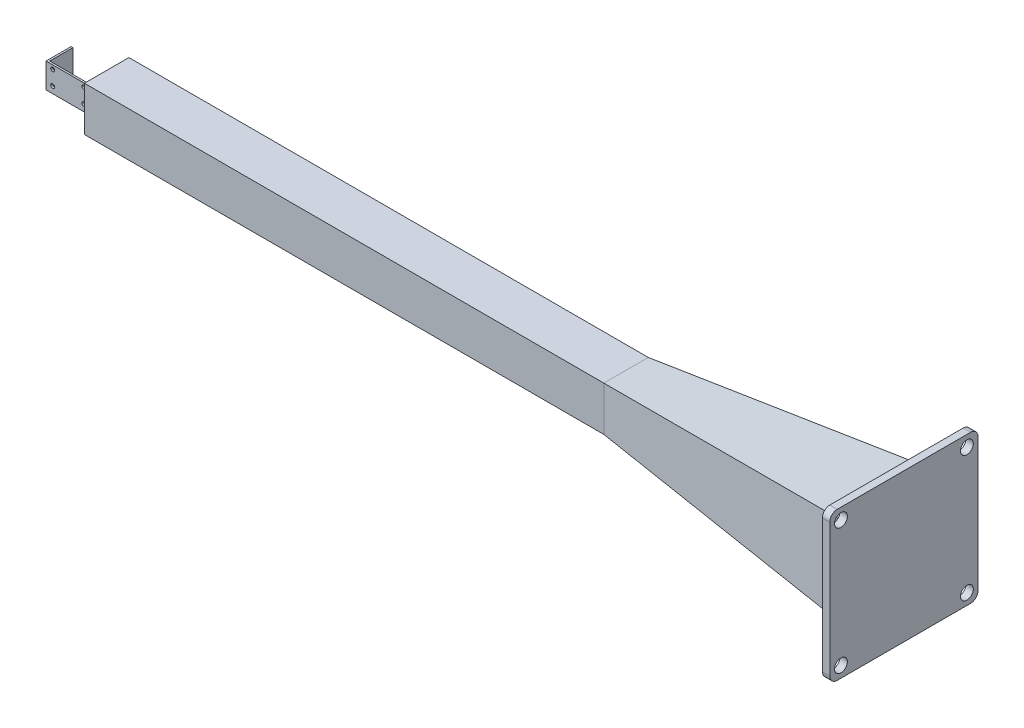
from build123d import *

# Parameters (mm, degrees)
SKETCH1_W            = 220
SKETCH1_H            = 130
SKETCH1_R            = 10.5
BOSS_EXTRUDE1_DEPTH  = 10
BOSS_EXTRUDE2_DEPTH  = 250
CUT_EXTRUDE1_DEPTH   = 5
SKETCH4_W            = 10
SKETCH4_H            = 135
BOSS_EXTRUDE3_DEPTH  = 250
SKETCH5_W            = 250
SKETCH5_H            = 135
BOSS_EXTRUDE4_DEPTH  = 2800
SKETCH8_W            = 115
SKETCH8_H            = 135
CUT_EXTRUDE2_DEPTH   = 10000
SKETCH12_W           = 170
SKETCH12_H           = 170
BOSS_EXTRUDE6_DEPTH  = 2800
CUT_EXTRUDE3_DEPTH   = 50
SKETCH15_W           = 170
SKETCH15_H           = 170
BOSS_EXTRUDE7_DEPTH  = 1524
SKETCH16_W           = 240
SKETCH16_H           = 240
BOSS_EXTRUDE8_DEPTH  = 4324
SKETCH17_W           = 240
SKETCH17_H           = 240
CUT_EXTRUDE4_DEPTH   = 20
SKETCH18_W           = 135
SKETCH18_H           = 135
BOSS_EXTRUDE9_DEPTH  = 20
SKETCH19_W           = 500
SKETCH19_H           = 500
SKETCH20_W           = 240
SKETCH20_H           = 240
SKETCH21_R           = 34.757471725
BOSS_EXTRUDE10_DEPTH = 40


with BuildPart() as part:
    # Sketch1 → Boss-Extrude1 (new body)
    with BuildSketch(Plane.XY):
        with Locations((6.239262286, -1.26777364)):
            Rectangle(SKETCH1_W, SKETCH1_H)
        with Locations((90.239262286, -40.26777364)):
            Circle(SKETCH1_R, mode=Mode.SUBTRACT)
        with Locations((-77.760737714, -40.26777364)):
            Circle(SKETCH1_R, mode=Mode.SUBTRACT)
        with Locations((-77.760737714, 37.73222636)):
            Circle(SKETCH1_R, mode=Mode.SUBTRACT)
        with Locations((90.239262286, 37.73222636)):
            Circle(SKETCH1_R, mode=Mode.SUBTRACT)
    extrude(amount=BOSS_EXTRUDE1_DEPTH)

    # Sketch2 → Boss-Extrude2 (add)
    with BuildSketch(Plane.XY.offset(10)):
        Polygon((-103.760737714, 63.73222636), (-113.760737714, 63.73222636), (-113.760737714, -66.26777364), (-113.760737714, -76.26777364), (116.239262286, -76.26777364), (116.239262286, -66.26777364), (-103.760737714, -66.26777364), align=None)
    extrude(amount=-BOSS_EXTRUDE2_DEPTH)

    # Sketch3 → Cut-Extrude1 (cut)
    with BuildSketch(Plane(origin=(0, 63.73222636, 0), x_dir=(1, 0, 0), z_dir=(0, 1, 0))):
        Polygon((116.239262286, 0), (-103.760737714, 0), (-103.760737714, 240), (-113.760737714, 240), (-113.760737714, -10), (116.239262286, -10), align=None)
    extrude(amount=-CUT_EXTRUDE1_DEPTH, mode=Mode.SUBTRACT)

    # Sketch4 → Boss-Extrude3 (add)
    with BuildSketch(Plane.XY.offset(10)):
        with Locations((121.239262286, -8.76777364)):
            Rectangle(SKETCH4_W, SKETCH4_H)
    extrude(amount=-BOSS_EXTRUDE3_DEPTH)


with BuildPart() as body_2:
    # Sketch5 → Boss-Extrude4 (new body)
    with BuildSketch(Plane(origin=(126.239262286, 0, 0), x_dir=(0, 0, -1), z_dir=(1, 0, 0))):
        with Locations((115, -8.76777364)):
            Rectangle(SKETCH5_W, SKETCH5_H)
    extrude(amount=BOSS_EXTRUDE4_DEPTH)


with BuildPart() as cut_extrude2_tool:
    # Sketch8 → Cut-Extrude2 (new body)
    with BuildSketch(Plane(origin=(2926.239262286, 0, 0), x_dir=(0, 0, -1), z_dir=(1, 0, 0))):
        with Locations((182.5, -8.76777364)):
            Rectangle(SKETCH8_W, SKETCH8_H)
    extrude(amount=-CUT_EXTRUDE2_DEPTH)


with BuildPart() as part_1:
    add(part.part)

    # Cut-Extrude2: cut by cut_extrude2_tool
    add(cut_extrude2_tool.part, mode=Mode.SUBTRACT)



with BuildPart() as body_2_1:
    add(body_2.part)

    # Cut-Extrude2: cut by cut_extrude2_tool
    add(cut_extrude2_tool.part, mode=Mode.SUBTRACT)


with BuildPart() as part_2:
    add(part_1.part)

    add(body_2_1.part)  # Boss-Extrude6 merges body 2
    # Sketch12 → Boss-Extrude6 (add)
    with BuildSketch(Plane(origin=(2926.239262286, 0, 0), x_dir=(0, 0, -1), z_dir=(1, 0, 0))):
        with Locations((57.5, -8.76777364)):
            Rectangle(SKETCH12_W, SKETCH12_H)
    extrude(amount=-BOSS_EXTRUDE6_DEPTH)

    # Sketch14 → Cut-Extrude3 (cut)
    with BuildSketch(Plane.XZ.offset(76.26777364)):
        Polygon((-103.760737714, 0), (116.239262286, 0), (116.239262286, -115), (116.239262286, -125), (-103.760737714, -125), (-103.760737714, -115), align=None)
    extrude(amount=-CUT_EXTRUDE3_DEPTH, mode=Mode.SUBTRACT)

    # Sketch15 → Boss-Extrude7 (add)
    with BuildSketch(Plane(origin=(2926.239262286, 0, 0), x_dir=(0, 0, -1), z_dir=(1, 0, 0))):
        with Locations((57.5, -8.76777364)):
            Rectangle(SKETCH15_W, SKETCH15_H)
    extrude(amount=BOSS_EXTRUDE7_DEPTH)

    # Sketch16 → Boss-Extrude8 (add)
    with BuildSketch(Plane.ZY.offset(-126.239262286)):
        with Locations((-57.5, -8.76777364)):
            Rectangle(SKETCH16_W, SKETCH16_H)
    extrude(amount=-BOSS_EXTRUDE8_DEPTH)

    # Sketch17 → Cut-Extrude4 (cut)
    with BuildSketch(Plane.ZY.offset(-126.239262286)):
        with Locations((-57.5, -8.76777364)):
            Rectangle(SKETCH17_W, SKETCH17_H)
    extrude(amount=-CUT_EXTRUDE4_DEPTH, mode=Mode.SUBTRACT)

    # Sketch18 → Boss-Extrude9 (add)
    with BuildSketch(Plane(origin=(126.239262286, 0, 0), x_dir=(0, 0, -1), z_dir=(1, 0, 0))):
        with Locations((57.5, -8.76777364)):
            Rectangle(SKETCH18_W, SKETCH18_H)
    extrude(amount=BOSS_EXTRUDE9_DEPTH)

    # Sketch19 → Loft1 section 0
    with BuildSketch(Plane(origin=(4450.239262286, 0, 0), x_dir=(0, 0, -1), z_dir=(1, 0, 0))):
        with Locations((57.5, -8.76777364)):
            Rectangle(SKETCH19_W, SKETCH19_H)
    # Sketch20 → Loft1 section 1
    with BuildSketch(Plane(origin=(2950.239262286, 0, 0), x_dir=(0, 0, -1), z_dir=(1, 0, 0))):
        with Locations((57.5, -8.76777364)):
            Rectangle(SKETCH20_W, SKETCH20_H)
    loft()

    # Sketch21 → Boss-Extrude10 (add)
    with BuildSketch(Plane(origin=(4450.239262286, 0, 0), x_dir=(0, 0, -1), z_dir=(1, 0, 0))):
        with BuildLine():
            Line((417.5, -408.76777364), (-302.5, -408.76777364))
            ThreePointArc((-302.5, -408.76777364), (-330.784271247, -397.052044888), (-342.5, -368.76777364))
            Line((-342.5, -368.76777364), (-342.5, 351.23222636))
            ThreePointArc((-342.5, 351.23222636), (-330.784271247, 379.516497607), (-302.5, 391.23222636))
            Line((-302.5, 391.23222636), (417.5, 391.23222636))
            ThreePointArc((417.5, 391.23222636), (445.784271247, 379.516497607), (457.5, 351.23222636))
            Line((457.5, 351.23222636), (457.5, -368.76777364))
            ThreePointArc((457.5, -368.76777364), (445.784271247, -397.052044888), (417.5, -408.76777364))
        make_face()
        with Locations((397.395923599, -348.663697239)):
            Circle(SKETCH21_R, mode=Mode.SUBTRACT)
        with Locations((-282.395923599, -348.663697239)):
            Circle(SKETCH21_R, mode=Mode.SUBTRACT)
        with Locations((-282.395923599, 331.128149959)):
            Circle(SKETCH21_R, mode=Mode.SUBTRACT)
        with Locations((397.395923599, 331.128149959)):
            Circle(SKETCH21_R, mode=Mode.SUBTRACT)
    extrude(amount=-BOSS_EXTRUDE10_DEPTH)


solid = part_2.part
